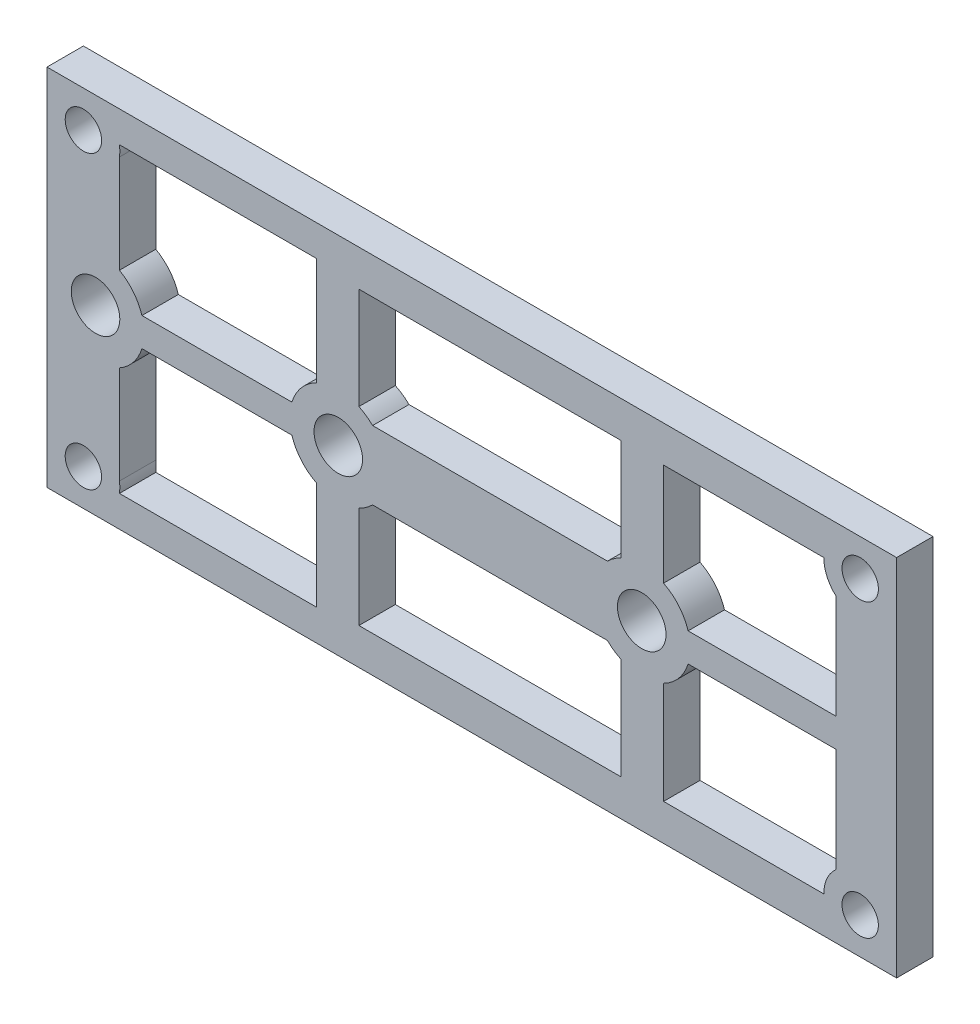
from build123d import *

# Parameters (mm, degrees)
SKETCH1_W           = 70
SKETCH1_H           = 30
BOSS_EXTRUDE1_DEPTH = 3
SKETCH2_R           = 1.5
SKETCH2_R_2         = 2
CUT_EXTRUDE2_DEPTH  = 4


with BuildPart() as part:
    # Sketch1 → Boss-Extrude1 (new body)
    with BuildSketch(Plane.XY):
        Rectangle(SKETCH1_W, SKETCH1_H)
    extrude(amount=BOSS_EXTRUDE1_DEPTH)

    # Sketch2 → Cut-Extrude2 (cut, through all)
    with BuildSketch(Plane.XY.offset(3)):
        with Locations((32, 12)):
            Circle(SKETCH2_R)
        with Locations((-32, 12)):
            Circle(SKETCH2_R)
        with Locations((32, -12)):
            Circle(SKETCH2_R)
        with Locations((-32, -12)):
            Circle(SKETCH2_R)
        with Locations((-11, 0)):
            Circle(SKETCH2_R_2)
        with Locations((-31, 0)):
            Circle(SKETCH2_R_2)
        with Locations((14, 0)):
            Circle(SKETCH2_R_2)
        with BuildLine():
            Line((-29.032472505, 12.440205142), (-12.8, 12.440205142))
            Line((-12.8, 12.440205142), (-12.8, 3.57211422))
            ThreePointArc((-12.8, 3.57211422), (-14.054873196, 2.582198629), (-14.821990136, 1.179996355))
            Line((-14.821990136, 1.179996355), (-27.178009864, 1.179996355))
            ThreePointArc((-27.178009864, 1.179996355), (-27.884686293, 2.508948087), (-29.032472505, 3.48264778))
            Line((-29.032472505, 3.48264778), (-29.032472505, 11.559794858))
            ThreePointArc((-29.032472505, 11.559794858), (-29, 12), (-29.032472505, 12.440205142))
        make_face()
        with BuildLine():
            Line((11.174466994, 2.831318285), (-8.174466994, 2.831318285))
            ThreePointArc((-8.174466994, 2.831318285), (-8.703062454, 3.274763794), (-9.3, 3.620773398))
            Line((-9.3, 3.620773398), (-9.3, 12))
            Line((-9.3, 12), (12.3, 12))
            Line((12.3, 12), (12.3, 3.620773398))
            ThreePointArc((12.3, 3.620773398), (11.703062454, 3.274763794), (11.174466994, 2.831318285))
        make_face()
        with BuildLine():
            Line((30, 1.179996355), (17.821990136, 1.179996355))
            ThreePointArc((17.821990136, 1.179996355), (17.054873196, 2.582198629), (15.8, 3.57211422))
            Line((15.8, 3.57211422), (15.8, 12))
            Line((15.8, 12), (29, 12))
            ThreePointArc((29, 12), (29.261387212, 10.775255129), (30, 9.763932023))
            Line((30, 9.763932023), (30, 1.179996355))
        make_face()
    cut_extrude2 = extrude(amount=-CUT_EXTRUDE2_DEPTH, mode=Mode.SUBTRACT)

    # Mirror1: Cut-Extrude2 across plane
    add(cut_extrude2.mirror(Plane.ZX), mode=Mode.SUBTRACT)


solid = part.part
